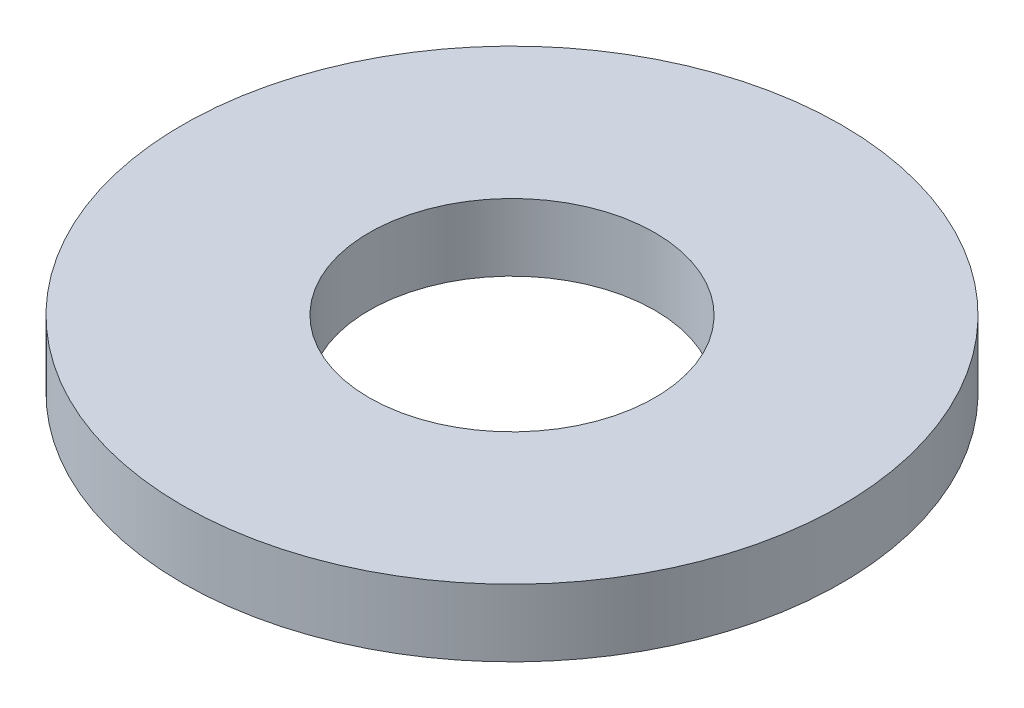
from build123d import *

# Parameters (mm, degrees)
SKETCH1_R           = 9.8
SKETCH1_R_2         = 4.25
BOSS_EXTRUDE1_DEPTH = 2


with BuildPart() as part:
    # Sketch1 → Boss-Extrude1 (new body)
    with BuildSketch(Plane(origin=(0, 0, 0), x_dir=(1, 0, 0), z_dir=(0, 1, 0))):
        Circle(SKETCH1_R)
        Circle(SKETCH1_R_2, mode=Mode.SUBTRACT)
    extrude(amount=BOSS_EXTRUDE1_DEPTH)


solid = part.part
